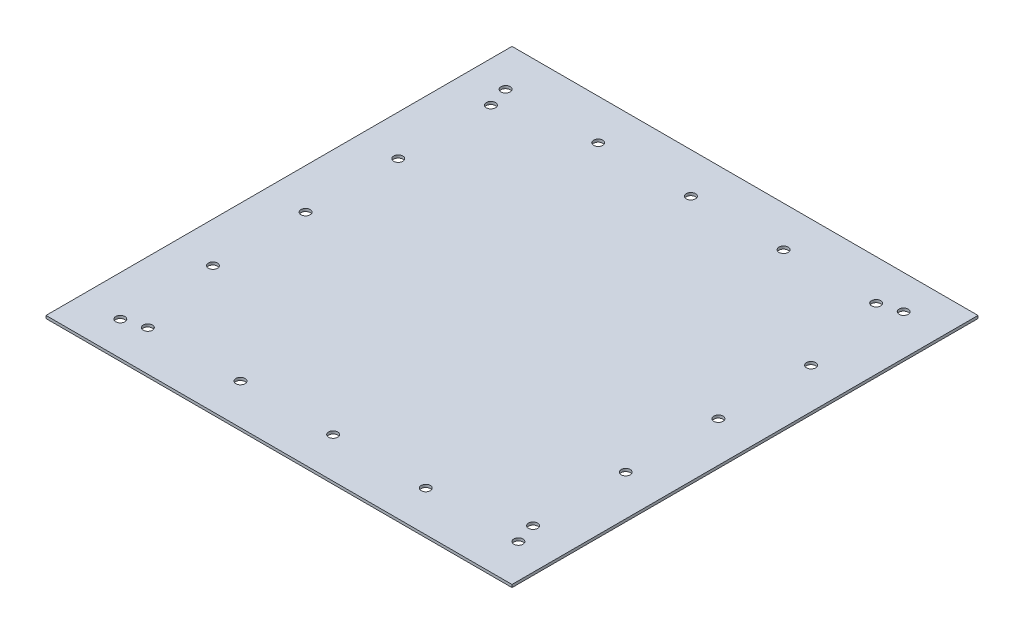
from build123d import *

# Parameters (mm, degrees)
SKETCH1_W           = 508
SKETCH1_H           = 508
BOSS_EXTRUDE1_DEPTH = 3
SKETCH3_R           = 5
CUT_EXTRUDE1_DEPTH  = 3


with BuildPart() as part:
    # Sketch1 → Boss-Extrude1 (new body)
    with BuildSketch(Plane(origin=(0, 0, 0), x_dir=(1, 0, 0), z_dir=(0, 1, 0))):
        Rectangle(SKETCH1_W, SKETCH1_H)
    extrude(amount=BOSS_EXTRUDE1_DEPTH)

    # Sketch3 → Cut-Extrude1 (cut)
    with BuildSketch(Plane.XZ):
        with Locations((217, 210)):
            Circle(SKETCH3_R)
        with Locations((116, 210)):
            Circle(SKETCH3_R)
        with Locations((15, 210)):
            Circle(SKETCH3_R)
        with Locations((-86, 210)):
            Circle(SKETCH3_R)
        with Locations((-187, 210)):
            Circle(SKETCH3_R)
        with Locations((-210, 217)):
            Circle(SKETCH3_R)
        with Locations((-210, 116)):
            Circle(SKETCH3_R)
        with Locations((-210, 15)):
            Circle(SKETCH3_R)
        with Locations((-210, -86)):
            Circle(SKETCH3_R)
        with Locations((-210, -187)):
            Circle(SKETCH3_R)
        with Locations((-217, -210)):
            Circle(SKETCH3_R)
        with Locations((-116, -210)):
            Circle(SKETCH3_R)
        with Locations((-15, -210)):
            Circle(SKETCH3_R)
        with Locations((86, -210)):
            Circle(SKETCH3_R)
        with Locations((187, -210)):
            Circle(SKETCH3_R)
        with Locations((210, -217)):
            Circle(SKETCH3_R)
        with Locations((210, -116)):
            Circle(SKETCH3_R)
        with Locations((210, -15)):
            Circle(SKETCH3_R)
        with Locations((210, 86)):
            Circle(SKETCH3_R)
        with Locations((210, 187)):
            Circle(SKETCH3_R)
    extrude(amount=-CUT_EXTRUDE1_DEPTH, mode=Mode.SUBTRACT)


solid = part.part
